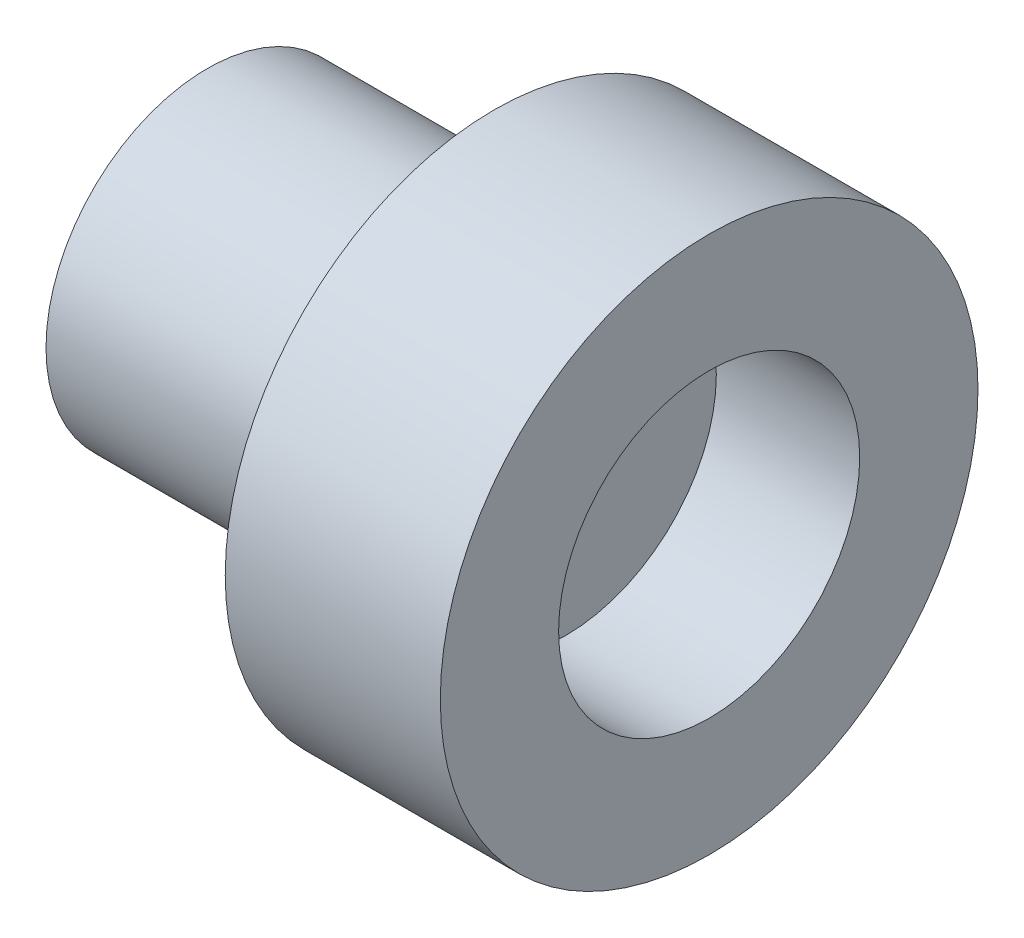
from build123d import *

# Parameters (mm, degrees)
FILLET1_R = 1


with BuildPart() as part:
    # Sketch1 → Revolve1 (revolve)
    with BuildSketch(Plane.XY):
        Polygon((0, 1.1), (3, 1.1), (3, 0), (5, 0), (5, 2.1), (7, 2.1), (7, 3.75), (4, 3.75), (4, 2.25), (0, 2.25), align=None)
    revolve(axis=Axis((0, 0, 0), (1, 0, 0)))

    # Fillet1
    fillet1_edges = [part.edges().sort_by_distance(p)[0] for p in [
        (4, -2.25, 0),
    ]]
    fillet(fillet1_edges, radius=FILLET1_R)


solid = part.part
